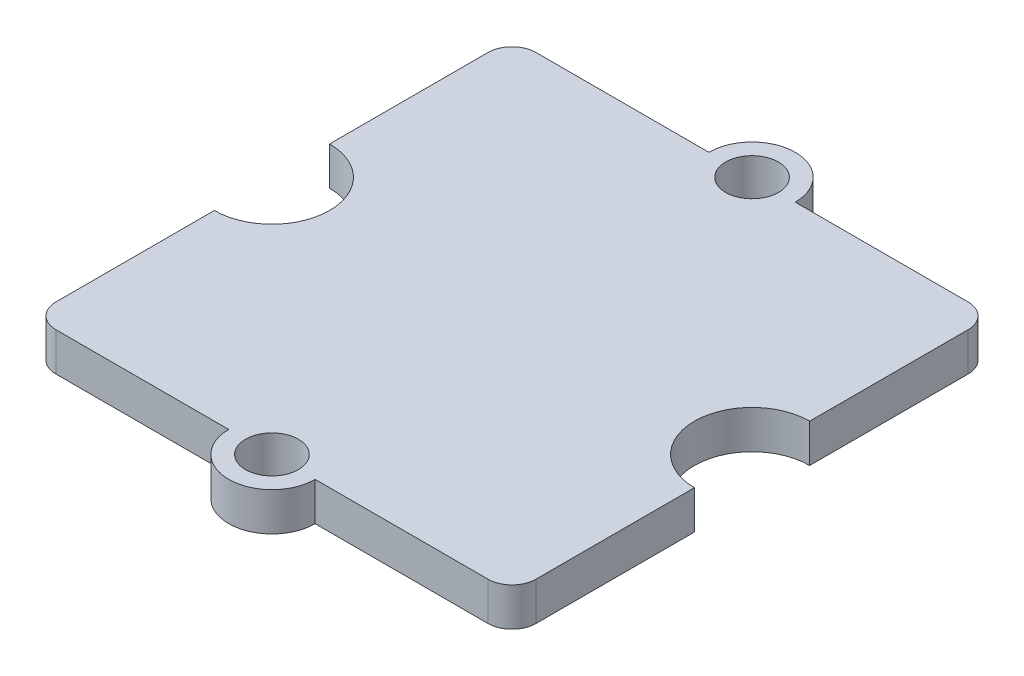
from build123d import *

# Parameters (mm, degrees)
ESQUISSE1_R        = 1.1
BOSS_EXTRU_1_DEPTH = 1.6


with BuildPart() as part:
    # Esquisse1 → Boss.-Extru.1 (new body)
    with BuildSketch(Plane(origin=(0, 0, 0), x_dir=(1, 0, 0), z_dir=(0, 1, 0))):
        with BuildLine():
            ThreePointArc((-1.8, -10), (0, -11.8), (1.8, -10))
            Line((1.8, -10), (9, -10))
            ThreePointArc((9, -10), (9.707106781, -9.707106781), (10, -9))
            Line((10, -9), (10, -2.4))
            ThreePointArc((10, -2.4), (7.6, 0), (10, 2.4))
            Line((10, 2.4), (10, 9))
            ThreePointArc((10, 9), (9.707106781, 9.707106781), (9, 10))
            Line((9, 10), (1.8, 10))
            ThreePointArc((1.8, 10), (0, 11.8), (-1.8, 10))
            Line((-1.8, 10), (-9, 10))
            ThreePointArc((-9, 10), (-9.707106781, 9.707106781), (-10, 9))
            Line((-10, 9), (-10, 2.4))
            ThreePointArc((-10, 2.4), (-7.6, 0), (-10, -2.4))
            Line((-10, -2.4), (-10, -9))
            ThreePointArc((-10, -9), (-9.707106781, -9.707106781), (-9, -10))
            Line((-9, -10), (-1.8, -10))
        make_face()
        with Locations(Location((0, -10, 0), (0, 0, 270))):  # turned: the seam where the file's is
            Circle(ESQUISSE1_R, mode=Mode.SUBTRACT)
        with Locations(Location((0, 10, 0), (0, 0, 270))):  # turned: the seam where the file's is
            Circle(ESQUISSE1_R, mode=Mode.SUBTRACT)
    extrude(amount=BOSS_EXTRU_1_DEPTH)


solid = part.part
